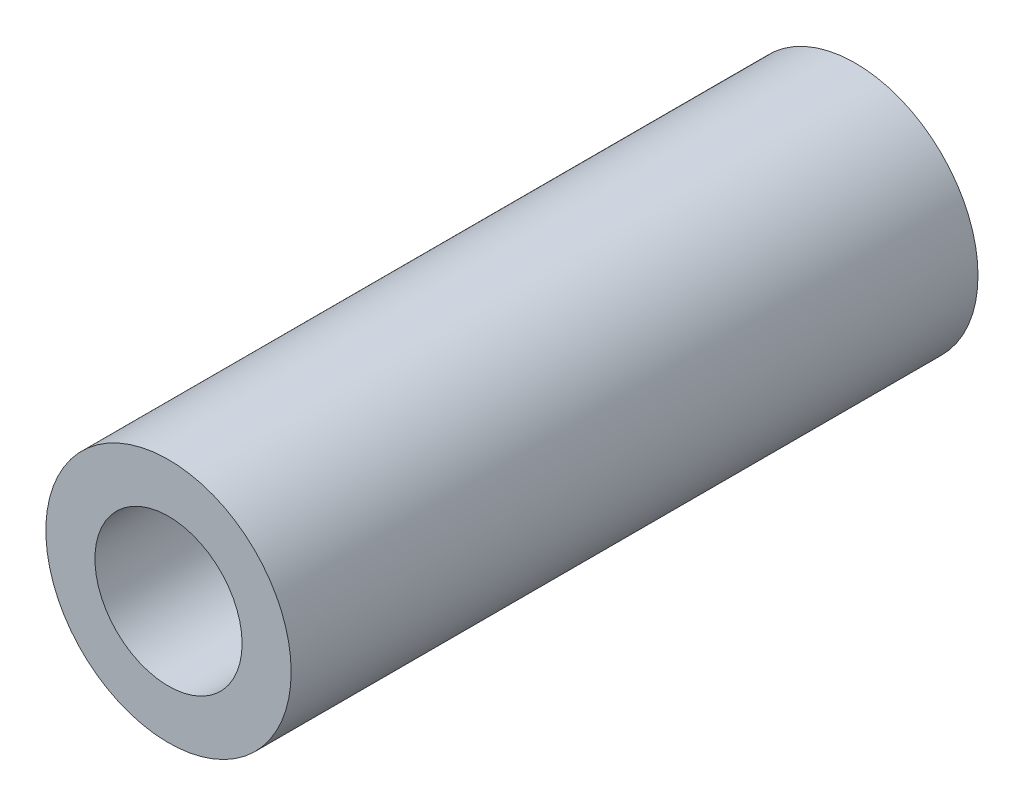
from build123d import *

# Parameters (mm, degrees)
SKETCH2_R           = 2.5
SKETCH2_R_2         = 1.5
BOSS_EXTRUDE1_DEPTH = 14


with BuildPart() as part:
    # Sketch2 → Boss-Extrude1 (new body)
    with BuildSketch(Plane.XY):
        Circle(SKETCH2_R)
        Circle(SKETCH2_R_2, mode=Mode.SUBTRACT)
    extrude(amount=BOSS_EXTRUDE1_DEPTH)


solid = part.part
